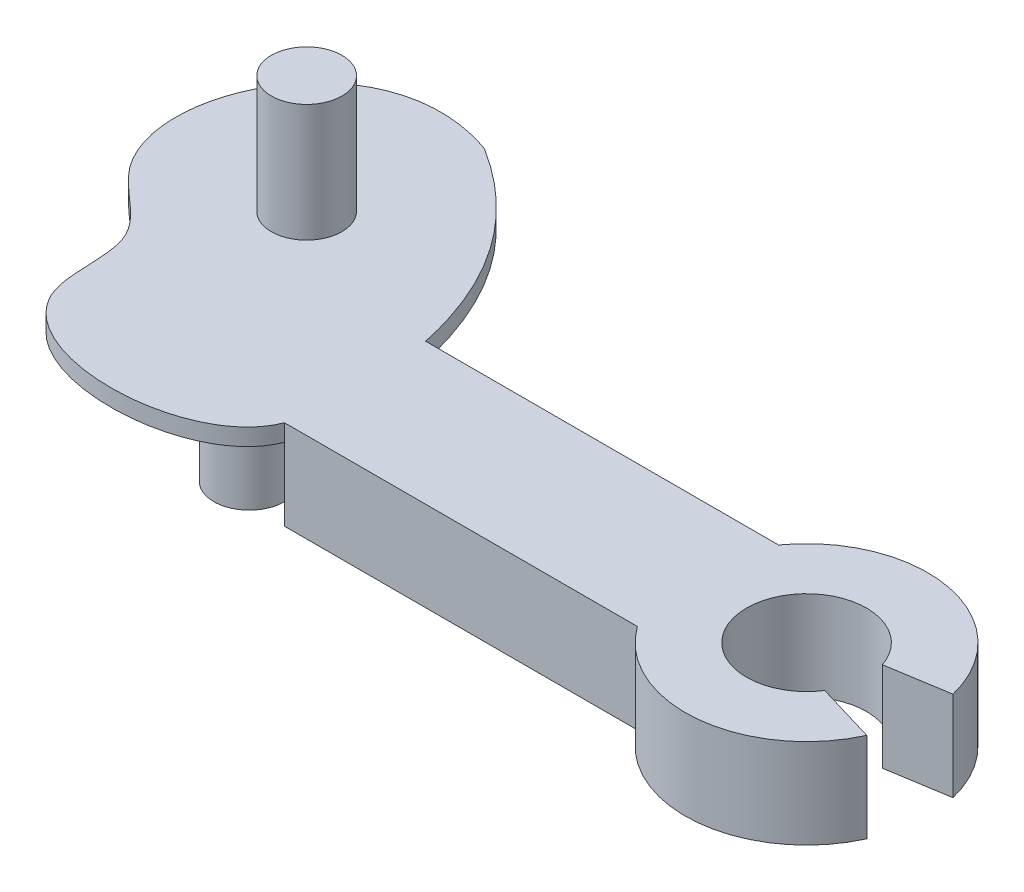
from build123d import *

# Parameters (mm, degrees)
SKETCH1_W               = 10
SKETCH1_H               = 4
BOSS_EXTRUDE2_DEPTH     = 2.54
SKETCH3_R               = 1
BOSS_EXTRUDE3_DEPTH     = 1.5
SKETCH4_R               = 1
BOSS_EXTRUDE5_DEPTH     = 1.5
SKETCH7_R               = 1
BOSS_EXTRUDE6_DEPTH     = 3.33
SKETCH8_R               = 1
BOSS_EXTRUDE7_DEPTH     = 1.3996
SKETCH9_R               = 1
CUT_EXTRUDE1_DEPTH      = 3.33
CUT_EXTRUDE1_DEPTH_BACK = 2.06
SKETCH10_R              = 1.862138251
CUT_EXTRUDE2_DEPTH      = 2.06


with BuildPart() as part:
    # Sketch1 → Boss-Extrude2 (new body)
    with BuildSketch(Plane(origin=(0, 0, 0), x_dir=(1, 0, 0), z_dir=(0, 1, 0))):
        with BuildLine():
            add(Edge.make_bspline(
                [(-3.892071286, 7.55845385), (-0.771451313, 5.601679727), (0, 2)],
                knots=[0, 0, 0, 1, 1, 1], degree=2))
            Line((0, 2), (0, -2))
            add(Edge.make_bspline(
                [(0, -2), (-0.807019421, -4.0986057), (-7.360800537, -4.196276699), (-6.343457725, 0.548340217), (-10.778232398, 2.929025773), (-8.051665625, 9.045483404), (-3.892071286, 7.55845385)],
                knots=[0, 0, 0, 0, 0.355860313, 0.470047608, 0.583542681, 1, 1, 1, 1], degree=3))
        make_face()
        with Locations((5, 0)):
            Rectangle(SKETCH1_W, SKETCH1_H)
        with BuildLine():
            Line((11.094, 0), (10, 0))
            Line((10, 0), (10, -2))
            ThreePointArc((10, -2), (13.128207579, -3.419757491), (15.922350304, -1.421217919))
            Line((15.922350304, -1.421217919), (14.22610231, -0.916014724))
            ThreePointArc((14.22610231, -0.916014724), (12.316807128, -1.631651606), (11.094, 0))
        make_face()
        with BuildLine():
            Line((10, 2), (10, 0))
            Line((10, 0), (11.094, 0))
            ThreePointArc((11.094, 0), (12.524636877, 1.678524205), (14.408639421, 0.531920615))
            Line((14.408639421, 0.531920615), (16.133188964, 0.810094479))
            ThreePointArc((16.133188964, 0.810094479), (13.448428406, 3.373152748), (10, 2))
        make_face()
    extrude(amount=BOSS_EXTRUDE2_DEPTH)

    # Sketch3 → Boss-Extrude3 (add)
    with BuildSketch(Plane(origin=(0, 2.54, 0), x_dir=(1, 0, 0), z_dir=(0, 1, 0))):
        with Locations((-3, 0)):
            Circle(SKETCH3_R)
    extrude(amount=BOSS_EXTRUDE3_DEPTH)

    # Sketch4 → Boss-Extrude5 (add)
    with BuildSketch(Plane(origin=(0, 0, 0), x_dir=(-1, 0, 0), z_dir=(0, -1, 0))):
        with Locations((4.872437244, 3.501336217)):
            Circle(SKETCH4_R)
    extrude(amount=BOSS_EXTRUDE5_DEPTH)

    # Sketch7 → Boss-Extrude6 (add)
    with BuildSketch(Plane(origin=(0, 2.54, 0), x_dir=(1, 0, 0), z_dir=(0, 1, 0))):
        with Locations((-4.872437244, 3.501336217)):
            Circle(SKETCH7_R)
    extrude(amount=BOSS_EXTRUDE6_DEPTH)

    # Sketch8 → Boss-Extrude7 (add)
    with BuildSketch(Plane(origin=(0, 0, 0), x_dir=(-1, 0, 0), z_dir=(0, -1, 0))):
        with Locations((3, 0)):
            Circle(SKETCH8_R)
    extrude(amount=BOSS_EXTRUDE7_DEPTH)

    # Sketch9 → Cut-Extrude1 (cut, two sides)
    with BuildSketch(Plane(origin=(0, 0, 0), x_dir=(-1, 0, 0), z_dir=(0, -1, 0))) as cut_extrude1_sk:
        with BuildLine():
            Line((0, 8.859088838), (0, 2))
            add(Edge.make_bspline(
                [(0, 2), (-2.175152806, 0.238184258), (0, -2)],
                knots=[0, 0, 0, 1, 1, 1], degree=2))
            Line((0, -2), (0, -4.672458071))
            Line((0, -4.672458071), (11.092635024, -4.672458071))
            Line((11.092635024, -4.672458071), (11.092635024, 8.859088838))
            Line((11.092635024, 8.859088838), (0, 8.859088838))
        make_face()
        with Locations((3, 0)):
            Circle(SKETCH9_R, mode=Mode.SUBTRACT)
    extrude(amount=CUT_EXTRUDE1_DEPTH, mode=Mode.SUBTRACT)
    extrude(cut_extrude1_sk.sketch, amount=-CUT_EXTRUDE1_DEPTH_BACK, mode=Mode.SUBTRACT)

    # Sketch10 → Cut-Extrude2 (cut)
    with BuildSketch(Plane(origin=(0, 2.54, 0), x_dir=(1, 0, 0), z_dir=(0, 1, 0))):
        with Locations((-2.940866893, -0.166273011)):
            Circle(SKETCH10_R)
    extrude(amount=CUT_EXTRUDE2_DEPTH, mode=Mode.SUBTRACT)


solid = part.part
